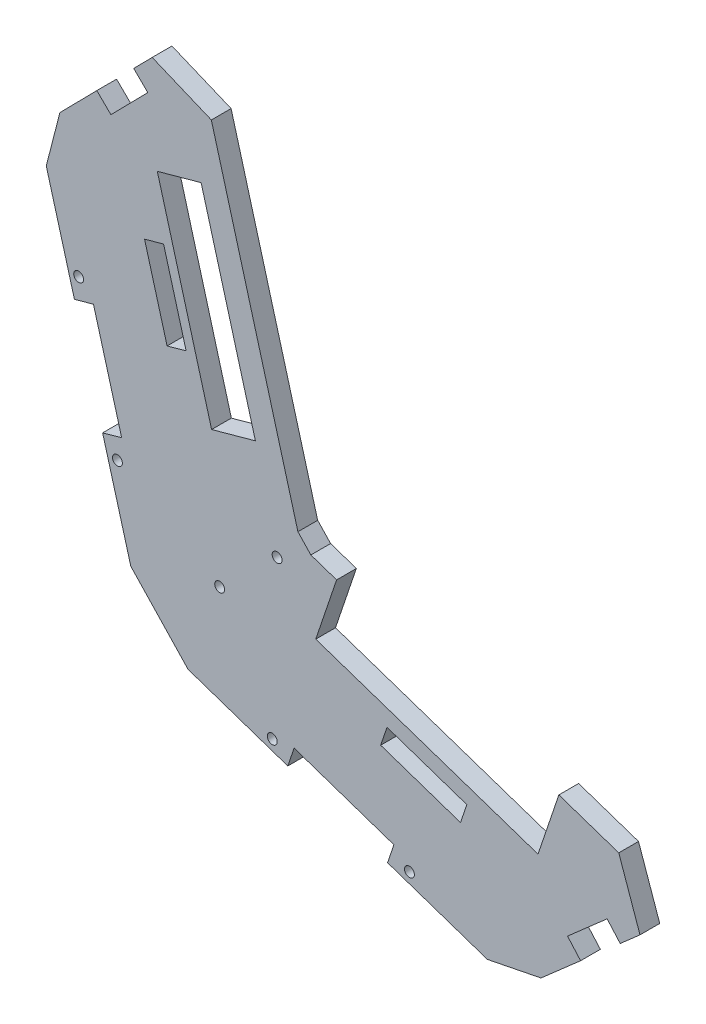
from build123d import *

# Parameters (mm, degrees)
SALIENTE_EXTRUIR1_DEPTH = 5
CROQUIS2_R              = 1.25
CORTAR_EXTRUIR1_DEPTH   = 10
CORTAR_EXTRUIR2_DEPTH   = 10
CORTAR_EXTRUIR3_DEPTH   = 10
CORTAR_EXTRUIR4_DEPTH   = 22
CORTAR_EXTRUIR5_DEPTH   = 10
SALIENTE_EXTRUIR3_DEPTH = 5
CORTAR_EXTRUIR7_DEPTH   = 5
CROQUIS9_R              = 1.25
CORTAR_EXTRUIR6_DEPTH   = 10


with BuildPart() as part:
    # Croquis1 → Saliente-Extruir1 (new body)
    with BuildSketch(Plane.XY):
        Polygon((94.71302301, -28.670259317), (124.784571975, -2.294096918), (121.487551675, 1.464846702), (33.971255169, 31.023525729), (29.162783478, 36.110627065), (4.554636507, 125.156882092), (0.987169784, 128.660192123), (-27.039310471, 100.120458339), (-30.489528096, 86.717422014), (-9.088639631, 9.652046375), (5.402210696, -5.678484568), (81.141270829, -31.381887447), align=None)
    extrude(amount=SALIENTE_EXTRUIR1_DEPTH)

    # Croquis2 → Cortar-Extruir1 (cut)
    with BuildSketch(Plane.XY.offset(5)):
        with Locations((27.933375513, 30.132453761)):
            Circle(CROQUIS2_R)
        with Locations((13.398800269, 16.393963215)):
            Circle(CROQUIS2_R)
    extrude(amount=-CORTAR_EXTRUIR1_DEPTH, mode=Mode.SUBTRACT)

    # Croquis3 → Cortar-Extruir2 (cut)
    with BuildSketch(Plane(origin=(0, 0, 0), x_dir=(-1, 0, 0), z_dir=(0, 0, -1))):
        Polygon((-93.962142428, -1.904403336), (-37.71071672, 17.094547759), (-41.550617787, 28.463591685), (-97.802043495, 9.46464059), align=None)
    extrude(amount=-CORTAR_EXTRUIR2_DEPTH, mode=Mode.SUBTRACT)

    # Croquis4 → Cortar-Extruir3 (cut)
    with BuildSketch(Plane(origin=(0, 0, 0), x_dir=(-1, 0, 0), z_dir=(0, 0, -1))):
        Polygon((-11.35589305, 49.864341228), (2.384432549, 99.58464479), (-8.700088084, 102.647878755), (-22.440413684, 52.927575193), align=None)
    extrude(amount=-CORTAR_EXTRUIR3_DEPTH, mode=Mode.SUBTRACT)

    # Croquis5 → Cortar-Extruir4 (cut)
    with BuildSketch(Plane(origin=(0, 0, 0), x_dir=(-1, 0, 0), z_dir=(0, 0, -1))):
        Polygon((23.359165427, 61.040727405), (18.541476581, 62.378589198), (11.406213682, 36.684248684), (16.223902529, 35.34638689), align=None)
        Polygon((-55.889136713, -22.812124691), (-57.49596723, -18.077349544), (-32.243833114, -9.507586787), (-30.637002597, -14.242361934), align=None)
        Polygon((-101.439852365, -16.119261564), (-111.46370202, -7.327207431), (-114.76072232, -11.086151051), (-104.736872665, -19.878205184), align=None)
        Polygon((14.129683663, 106.130392902), (4.787523578, 115.643637497), (8.354990301, 119.146947529), (17.697150386, 109.633702934), align=None)
    extrude(amount=-CORTAR_EXTRUIR4_DEPTH, mode=Mode.SUBTRACT)

    # Croquis6 → Cortar-Extruir5 (cut)
    with BuildSketch(Plane(origin=(0, 0, 0), x_dir=(-1, 0, 0), z_dir=(0, 0, -1))):
        Polygon((-55.751519014, 6.80303632), (-75.953226307, -0.052773886), (-74.34639579, -4.787549032), (-54.144688498, 2.068261173), align=None)
        Polygon((0.798726555, 84.444359548), (-4.909483764, 63.888887136), (-0.091794917, 62.551025343), (5.616415401, 83.106497755), align=None)
    extrude(amount=-CORTAR_EXTRUIR5_DEPTH, mode=Mode.SUBTRACT)

    # Croquis10 → Saliente-Extruir3 (add)
    with BuildSketch(Plane(origin=(0, 0, 0), x_dir=(-1, 0, 0), z_dir=(0, 0, -1))):
        Polygon((-121.487551675, 1.464846702), (-97.802043495, 9.46464059), (-99.242006394, 13.728032063), (-122.927514575, 5.728238174), align=None)
        Polygon((-29.162783478, 36.110627065), (-4.554636507, 125.156882092), (-8.892057625, 126.355538861), (-33.202024845, 38.388267562), (-36.472242051, 34.928555747), (-42.990580687, 32.726983158), (-41.550617787, 28.463591685), (-33.971255169, 31.023525729), align=None)
    extrude(amount=-SALIENTE_EXTRUIR3_DEPTH)

    # Croquis11 → Cortar-Extruir7 (cut)
    with BuildSketch(Plane(origin=(0, 0, 0), x_dir=(-1, 0, 0), z_dir=(0, 0, -1))):
        Polygon((-119.772647147, -6.690123985), (-114.40073163, 8.608163974), (-122.927514575, 5.728238174), (-121.487551675, 1.464846702), (-124.784571975, -2.294096918), align=None)
        Polygon((3.683910258, 123.903569826), (-11.289371163, 117.680696626), (-8.892057625, 126.355538861), (-4.554636507, 125.156882092), (-0.987169784, 128.660192123), align=None)
    extrude(amount=-CORTAR_EXTRUIR7_DEPTH, mode=Mode.SUBTRACT)

    # Croquis9 → Cortar-Extruir6 (cut)
    with BuildSketch(Plane(origin=(0, 0, 0), x_dir=(-1, 0, 0), z_dir=(0, 0, -1))):
        with Locations((-26.705642709, -10.268143844)):
            Circle(CROQUIS9_R)
        with Locations((-61.427327118, -22.051567634)):
            Circle(CROQUIS9_R)
        with Locations((12.477196312, 31.19762894)):
            Circle(CROQUIS9_R)
        with Locations((22.288182797, 66.527347148)):
            Circle(CROQUIS9_R)
    extrude(amount=-CORTAR_EXTRUIR6_DEPTH, mode=Mode.SUBTRACT)


solid = part.part
